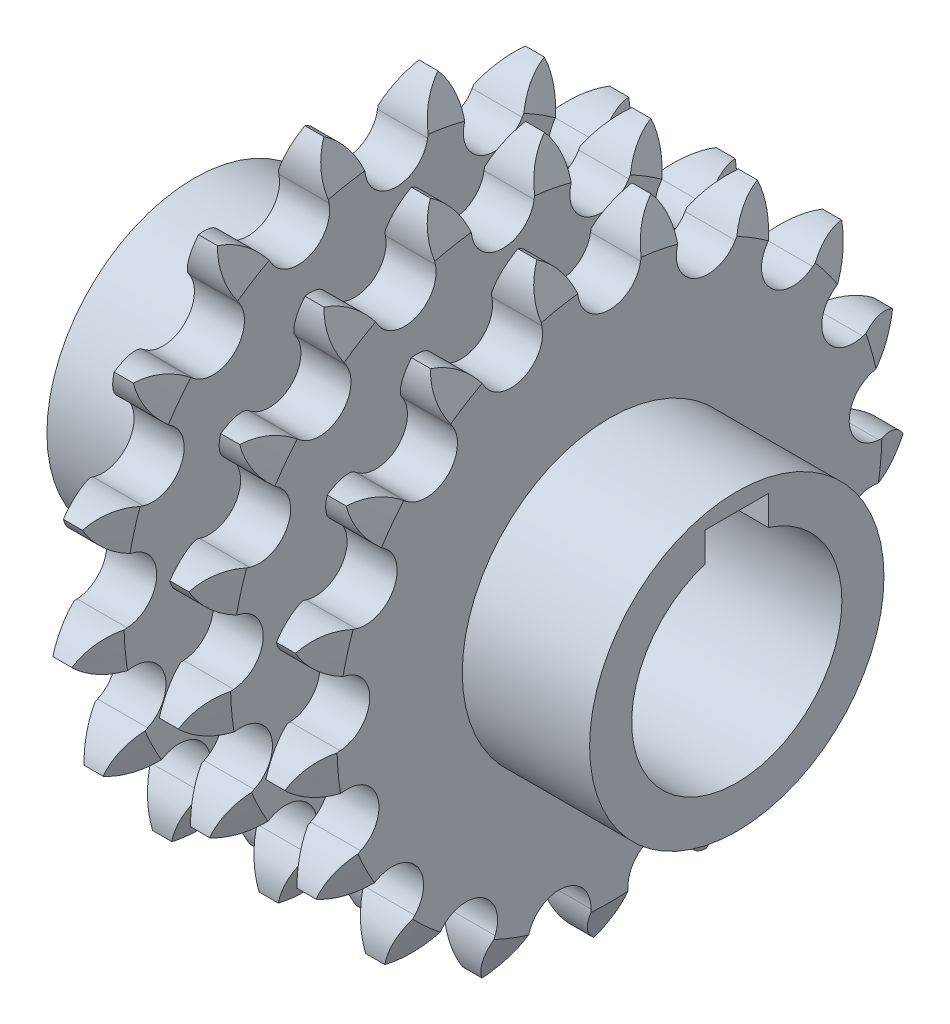
from build123d import *

# Parameters (mm, degrees)
SKETCH2_R                = 29.915
CUT_EXTRUDE1_DEPTH       = 5.76
LPATTERN4_COUNT          = 3
LPATTERN4_PITCH          = 10.13
SKETCH4_R                = 14
BOSS_EXTRUDE1_DEPTH      = 14.49
BOSS_EXTRUDE1_DEPTH_BACK = 37.13
SKETCH5_R                = 10
CUT_EXTRUDE2_DEPTH       = 52.62
SKETCH6_W                = 6
SKETCH6_H                = 2.8
CUT_EXTRUDE3_DEPTH       = 8


with BuildPart() as part:
    # Sketch1 → Revolve1 (revolve)
    with BuildSketch(Plane.XY):
        Polygon((-2.38, 0), (2.38, 0), (2.38, 25.915), (0.75, 29.915), (-0.75, 29.915), (-2.38, 25.915), align=None)
    revolve(axis=Axis((-2.38, 0, 0), (1, 0, 0)))

    # Sketch2 → Cut-Extrude1 (cut, through all)
    with BuildSketch(Plane(origin=(2.38, 0, 0), x_dir=(0, 0, -1), z_dir=(1, 0, 0))):
        Circle(SKETCH2_R)
        with BuildLine():
            ThreePointArc((-2.964048343, 25.451947714), (0, 22.915), (2.964048343, 25.451947714))
            ThreePointArc((2.964048343, 25.451947714), (3.787407004, 27.517904373), (5.425233802, 29.02243745))
            ThreePointArc((5.425233802, 29.02243745), (6.408961773, 27.027850856), (6.430411233, 24.803972189))
            ThreePointArc((6.430411233, 24.803972189), (8.277852781, 21.367601137), (11.958196766, 22.662496665))
            ThreePointArc((11.958196766, 22.662496665), (13.472265478, 24.291512422), (15.54299352, 25.102796454))
            ThreePointArc((15.54299352, 25.102796454), (15.739764749, 22.887536314), (14.95640814, 20.806082777))
            ThreePointArc((14.95640814, 20.806082777), (15.437735674, 16.934389338), (19.337324454, 16.812349865))
            ThreePointArc((19.337324454, 16.812349865), (21.337619847, 17.784417115), (23.561585836, 17.792883697))
            ThreePointArc((23.561585836, 17.792883697), (22.944825279, 15.656133169), (21.462459252, 13.998216596))
            ThreePointArc((21.462459252, 13.998216596), (20.512666821, 10.214094423), (24.104839322, 8.691602055))
            ThreePointArc((24.104839322, 8.691602055), (26.32121042, 8.87543773), (28.398055426, 8.079943403))
            ThreePointArc((28.398055426, 8.079943403), (27.051060013, 6.310282486), (25.069886314, 5.299813696))
            ThreePointArc((25.069886314, 5.299813696), (22.81724865, 2.114329457), (25.61686207, -0.602994775))
            ThreePointArc((25.61686207, -0.602994775), (27.749975675, -1.232218701), (29.399210271, -2.72423802))
            ThreePointArc((29.399210271, -2.72423802), (27.503899198, -3.887806813), (25.291486312, -4.114358411))
            ThreePointArc((25.291486312, -4.114358411), (22.040234613, -6.270987418), (23.669185647, -9.816153818))
            ThreePointArc((23.669185647, -9.816153818), (25.430952947, -11.173457169), (26.429838863, -13.160496003))
            ThreePointArc((26.429838863, -13.160496003), (24.242184391, -13.56082626), (22.097330939, -12.972863615))
            ThreePointArc((22.097330939, -12.972863615), (18.286564763, -13.809372693), (18.524854548, -17.703586896))
            ThreePointArc((18.524854548, -17.703586896), (19.677339105, -19.605658332), (19.890971263, -21.819356076))
            ThreePointArc((19.890971263, -21.819356076), (17.706428252, -21.402380976), (15.918808577, -20.079311704))
            ThreePointArc((15.918808577, -20.079311704), (12.063193012, -19.482725665), (10.878639192, -23.200052464))
            ThreePointArc((10.878639192, -23.200052464), (11.266191582, -25.390006698), (10.665717775, -27.531391206))
            ThreePointArc((10.665717775, -27.531391206), (8.779320862, -26.353425547), (7.590362907, -24.473937483))
            ThreePointArc((7.590362907, -24.473937483), (4.210620201, -22.524828579), (1.763203332, -25.563222391))
            ThreePointArc((1.763203332, -25.563222391), (1.333482457, -27.745293969), (0, -29.525159396))
            ThreePointArc((0, -29.525159396), (-1.333482457, -27.745293969), (-1.763203332, -25.563222391))
            ThreePointArc((-1.763203332, -25.563222391), (-4.210620201, -22.524828579), (-7.590362907, -24.473937483))
            ThreePointArc((-7.590362907, -24.473937483), (-8.779320862, -26.353425547), (-10.665717775, -27.531391206))
            ThreePointArc((-10.665717775, -27.531391206), (-11.266191582, -25.390006698), (-10.878639192, -23.200052464))
            ThreePointArc((-10.878639192, -23.200052464), (-12.063193012, -19.482725665), (-15.918808577, -20.079311704))
            ThreePointArc((-15.918808577, -20.079311704), (-17.706428252, -21.402380976), (-19.890971263, -21.819356076))
            ThreePointArc((-19.890971263, -21.819356076), (-19.677339105, -19.605658332), (-18.524854548, -17.703586896))
            ThreePointArc((-18.524854548, -17.703586896), (-18.286564763, -13.809372693), (-22.097330939, -12.972863615))
            ThreePointArc((-22.097330939, -12.972863615), (-24.242184391, -13.56082626), (-26.429838863, -13.160496003))
            ThreePointArc((-26.429838863, -13.160496003), (-25.430952947, -11.173457169), (-23.669185647, -9.816153818))
            ThreePointArc((-23.669185647, -9.816153818), (-22.040234613, -6.270987418), (-25.291486312, -4.114358411))
            ThreePointArc((-25.291486312, -4.114358411), (-27.503899198, -3.887806813), (-29.399210271, -2.72423802))
            ThreePointArc((-29.399210271, -2.72423802), (-27.749975675, -1.232218701), (-25.61686207, -0.602994775))
            ThreePointArc((-25.61686207, -0.602994775), (-22.81724865, 2.114329457), (-25.069886314, 5.299813696))
            ThreePointArc((-25.069886314, 5.299813696), (-27.051060013, 6.310282486), (-28.398055426, 8.079943403))
            ThreePointArc((-28.398055426, 8.079943403), (-26.32121042, 8.87543773), (-24.104839322, 8.691602055))
            ThreePointArc((-24.104839322, 8.691602055), (-20.512666821, 10.214094423), (-21.462459252, 13.998216596))
            ThreePointArc((-21.462459252, 13.998216596), (-22.944825279, 15.656133169), (-23.561585836, 17.792883697))
            ThreePointArc((-23.561585836, 17.792883697), (-21.337619847, 17.784417115), (-19.337324454, 16.812349865))
            ThreePointArc((-19.337324454, 16.812349865), (-15.437735674, 16.934389338), (-14.95640814, 20.806082777))
            ThreePointArc((-14.95640814, 20.806082777), (-15.739764749, 22.887536314), (-15.54299352, 25.102796454))
            ThreePointArc((-15.54299352, 25.102796454), (-13.472265478, 24.291512422), (-11.958196766, 22.662496665))
            ThreePointArc((-11.958196766, 22.662496665), (-8.277852781, 21.367601137), (-6.430411233, 24.803972189))
            ThreePointArc((-6.430411233, 24.803972189), (-6.408961773, 27.027850856), (-5.425233802, 29.02243745))
            ThreePointArc((-5.425233802, 29.02243745), (-3.787407004, 27.517904373), (-2.964048343, 25.451947714))
        make_face(mode=Mode.SUBTRACT)
    extrude(amount=-CUT_EXTRUDE1_DEPTH, mode=Mode.SUBTRACT)


with BuildPart() as lpattern4_1:
    # LPattern4: pattern copy
    add(part.part.moved(Location(Vector(1, 0, 0) * (1 * LPATTERN4_PITCH))))


with BuildPart() as lpattern4_2:
    # LPattern4: pattern copy
    add(part.part.moved(Location(Vector(1, 0, 0) * (2 * LPATTERN4_PITCH))))


with BuildPart() as part_1:
    add(part.part)

    add(lpattern4_1.part)  # Boss-Extrude1 merges LPattern4_1

    add(lpattern4_2.part)  # Boss-Extrude1 merges LPattern4_2
    # Sketch4 → Boss-Extrude1 (add, two sides)
    with BuildSketch(Plane.ZY.offset(2.38)) as boss_extrude1_sk:
        Circle(SKETCH4_R)
    extrude(amount=BOSS_EXTRUDE1_DEPTH)
    extrude(boss_extrude1_sk.sketch, amount=-BOSS_EXTRUDE1_DEPTH_BACK)

    # Sketch5 → Cut-Extrude2 (cut, through all)
    with BuildSketch(Plane(origin=(34.75, 0, 0), x_dir=(0, 0, -1), z_dir=(1, 0, 0))):
        Circle(SKETCH5_R)
    extrude(amount=-CUT_EXTRUDE2_DEPTH, mode=Mode.SUBTRACT)

    # Sketch6 → Cut-Extrude3 (cut)
    with BuildSketch(Plane(origin=(34.75, 0, 0), x_dir=(0, 0, -1), z_dir=(1, 0, 0))):
        with Locations((0, 10.939392014)):
            Rectangle(SKETCH6_W, SKETCH6_H)
    extrude(amount=-CUT_EXTRUDE3_DEPTH, mode=Mode.SUBTRACT)


solid = part_1.part
